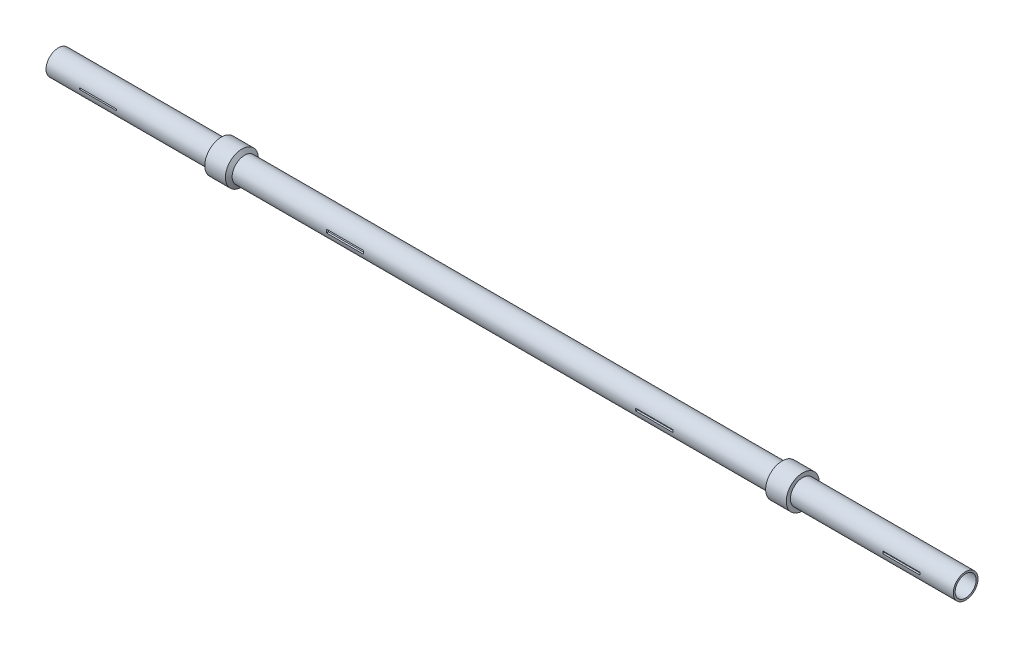
from build123d import *

# Parameters (mm, degrees)
SKETCH5_R               = 12.721239978
CUT_EXTRUDE1_DEPTH      = 1100
CUT_EXTRUDE1_DEPTH_BACK = 1100
SKETCH4_4_W             = 45.098856354
SKETCH4_4_H             = 1.822787056
SKETCH4_4_W_2           = 44.950171806
SKETCH4_4_H_2           = 4.046424606
SKETCH4_4_W_3           = 45.020896592
SKETCH4_4_H_3           = 3.001393106
CUT_EXTRUDE2_DEPTH      = 21
CUT_EXTRUDE2_DEPTH_BACK = 21


with BuildPart() as part:
    # Sketch4 → Revolve-Thin1 (revolve)
    with BuildSketch(Plane.XY):
        Polygon((-243.719110407, 0), (-243.719110407, 15), (-46.219110407, 15), (-46.219110407, 20), (-21.219110407, 20), (-18.010973852, 15), (630.572753038, 15), (633.780889593, 20), (658.780889593, 20), (658.780889593, 15), (856.280889593, 15), (856.280889593, 0), (846.280889593, 0), (846.280889593, 5), (648.780889593, 5), (648.780889593, 10), (639.246054132, 10), (636.037917577, 5), (-23.476138391, 5), (-26.684274946, 10), (-36.219110407, 10), (-36.219110407, 5), (-233.719110407, 5), (-233.719110407, 0), align=None)
    revolve(axis=Axis((-243.719110407, 0, 0), (1, 0, 0)))

    # Sketch5 → Cut-Extrude1 (cut, two sides)
    with BuildSketch(Plane.ZY.offset(243.719110407)) as cut_extrude1_sk:
        Circle(SKETCH5_R)
    extrude(amount=CUT_EXTRUDE1_DEPTH, mode=Mode.SUBTRACT)
    extrude(cut_extrude1_sk.sketch, amount=-CUT_EXTRUDE1_DEPTH_BACK, mode=Mode.SUBTRACT)

    # Sketch4_4 → Cut-Extrude2 (cut, two sides)
    with BuildSketch(Plane.XY) as cut_extrude2_sk:
        with Locations((-180.719110407, 0)):
            Rectangle(SKETCH4_4_W, SKETCH4_4_H)
        with Locations((118.780889593, 0)):
            Rectangle(SKETCH4_4_W_2, SKETCH4_4_H_2)
        with Locations((493.780889593, 0)):
            Rectangle(SKETCH4_4_W_3, SKETCH4_4_H_3)
        with Locations((793.280889593, 0)):
            Rectangle(SKETCH4_4_W_3, SKETCH4_4_H_3)
    extrude(amount=CUT_EXTRUDE2_DEPTH, mode=Mode.SUBTRACT)
    extrude(cut_extrude2_sk.sketch, amount=-CUT_EXTRUDE2_DEPTH_BACK, mode=Mode.SUBTRACT)


solid = part.part
